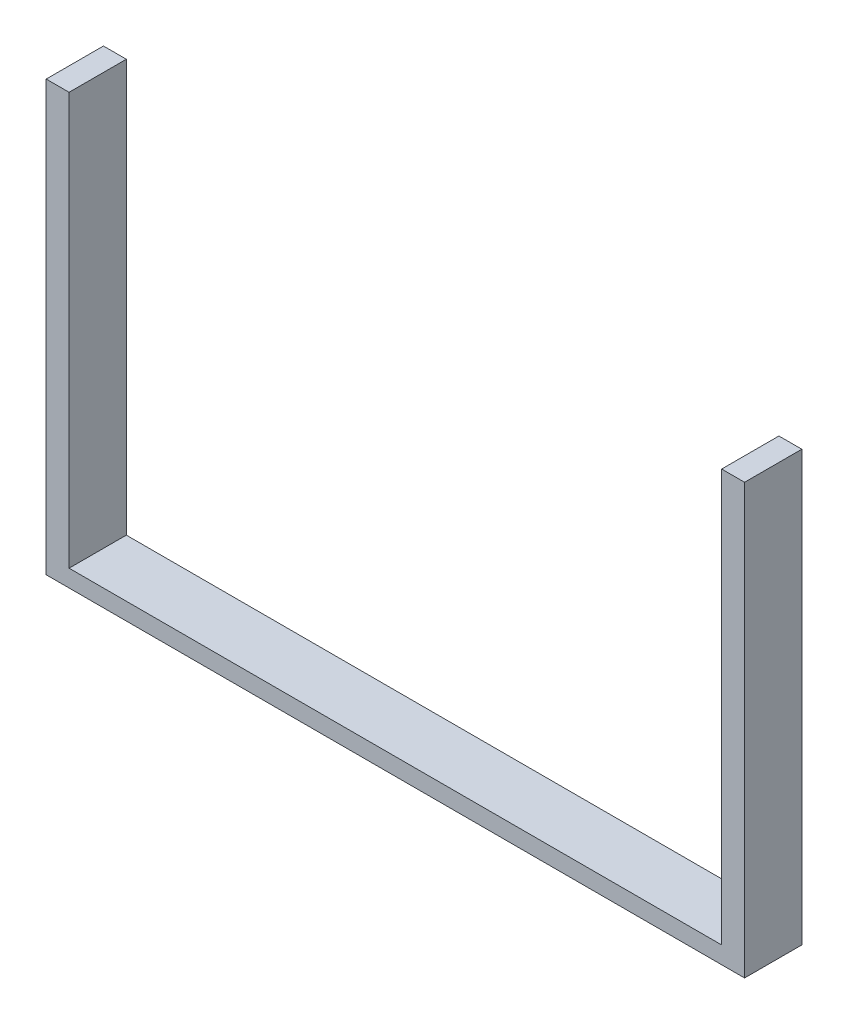
from build123d import *

# Parameters (mm, degrees)
SKETCH1_W             = 4
SKETCH1_H             = 75
BOSS_EXTRUDE1_DEPTH   = 10
BOSS_EXTRUDE1_2_DEPTH = 10
SKETCH3_W             = 122
SKETCH3_H             = 3
BOSS_EXTRUDE2_DEPTH   = 10


with BuildPart() as part:
    # Sketch1 → Boss-Extrude1 (new body)
    with BuildSketch(Plane.XY):
        with Locations((-59, 37.5)):
            Rectangle(SKETCH1_W, SKETCH1_H)
    extrude(amount=BOSS_EXTRUDE1_DEPTH)



with BuildPart() as body_2:
    # Sketch1 → Boss-Extrude1 2 (new body)
    with BuildSketch(Plane.XY):
        with Locations((59, 37.5)):
            Rectangle(SKETCH1_W, SKETCH1_H)
    extrude(amount=BOSS_EXTRUDE1_2_DEPTH)


with BuildPart() as part_1:
    add(part.part)

    add(body_2.part)  # Boss-Extrude2 merges body 2
    # Sketch3 → Boss-Extrude2 (add)
    with BuildSketch(Plane.XY):
        with Locations((0, 1.5)):
            Rectangle(SKETCH3_W, SKETCH3_H)
    extrude(amount=BOSS_EXTRUDE2_DEPTH)


solid = part_1.part
